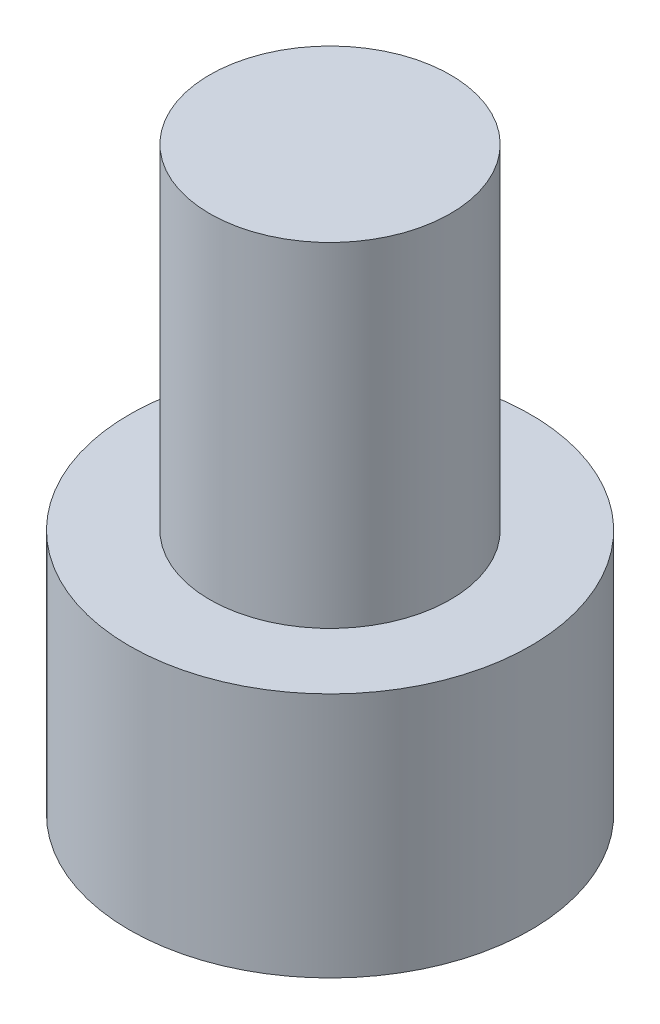
from build123d import *

# Parameters (mm, degrees)
SKETCH1_R           = 2.8575
BOSS_EXTRUDE1_DEPTH = 3.5052
CUT_EXTRUDE1_DEPTH  = 1.9558
SKETCH3_R           = 1.7145
BOSS_EXTRUDE2_DEPTH = 4.7625


with BuildPart() as part:
    # Sketch1 → Boss-Extrude1 (new body)
    with BuildSketch(Plane(origin=(0, 0, 0), x_dir=(1, 0, 0), z_dir=(0, 1, 0))):
        Circle(SKETCH1_R)
    extrude(amount=BOSS_EXTRUDE1_DEPTH)

    # Sketch2 → Cut-Extrude1 (cut)
    with BuildSketch(Plane.XZ):
        Polygon((1.603951217, 0), (0.801975608, 1.3890625), (-0.801975608, 1.3890625), (-1.603951217, 0), (-0.801975608, -1.3890625), (0.801975608, -1.3890625), align=None)
    extrude(amount=-CUT_EXTRUDE1_DEPTH, mode=Mode.SUBTRACT)

    # Sketch3 → Boss-Extrude2 (add)
    with BuildSketch(Plane(origin=(0, 3.5052, 0), x_dir=(1, 0, 0), z_dir=(0, 1, 0))):
        Circle(SKETCH3_R)
    extrude(amount=BOSS_EXTRUDE2_DEPTH)


solid = part.part
